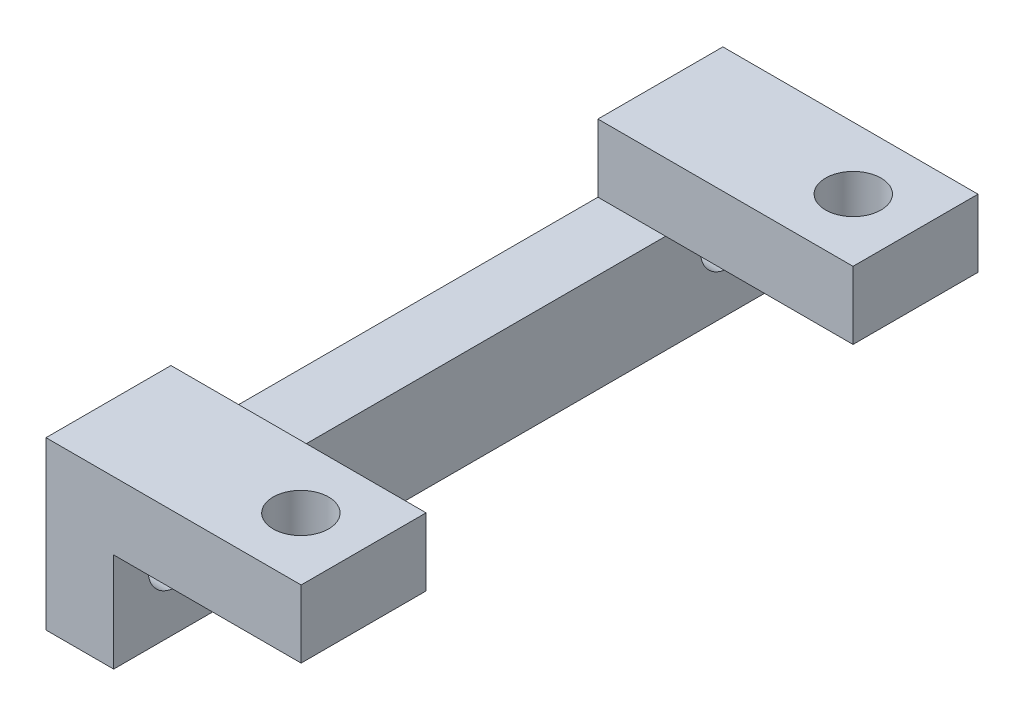
from build123d import *

# Parameters (mm, degrees)
SKETCH1_W             = 33.02
SKETCH1_H             = 4.826
BOSS_EXTRUDE1_DEPTH   = 3.302
SKETCH2_W             = 6.096
SKETCH2_H             = 3.302
BOSS_EXTRUDE2_DEPTH   = 12.446
F_6_32_TAPPED_HOLE1_D = 2.7051
F_6_32_TAPPED_HOLE2_D = 2.7051


with BuildPart() as part:
    # Sketch1 → Boss-Extrude1 (new body)
    with BuildSketch(Plane(origin=(0, 0, 0), x_dir=(0, 0, -1), z_dir=(1, 0, 0))):
        with Locations((16.51, 2.413)):
            Rectangle(SKETCH1_W, SKETCH1_H)
    extrude(amount=BOSS_EXTRUDE1_DEPTH)

    # Sketch2 → Boss-Extrude2 (add)
    with BuildSketch(Plane.ZY):
        with Locations((-29.972, 6.477)):
            Rectangle(SKETCH2_W, SKETCH2_H)
        with Locations((-3.048, 6.477)):
            Rectangle(SKETCH2_W, SKETCH2_H)
    extrude(amount=-BOSS_EXTRUDE2_DEPTH)

    # #6-32 Tapped Hole1 (through all)
    with Locations(Plane(origin=(3.302, 0, 0), x_dir=(0, 0, -1), z_dir=(1, 0, 0))):
        with Locations((3.0353, 3.302), (29.9847, 3.302)):
            Hole(F_6_32_TAPPED_HOLE1_D / 2)

    # #6-32 Tapped Hole2 (through all)
    with Locations(Plane(origin=(0, 8.128, 0), x_dir=(1, 0, 0), z_dir=(0, 1, 0))):
        with Locations((9.398, 3.0353), (9.398, 29.9847)):
            Hole(F_6_32_TAPPED_HOLE2_D / 2)


solid = part.part
